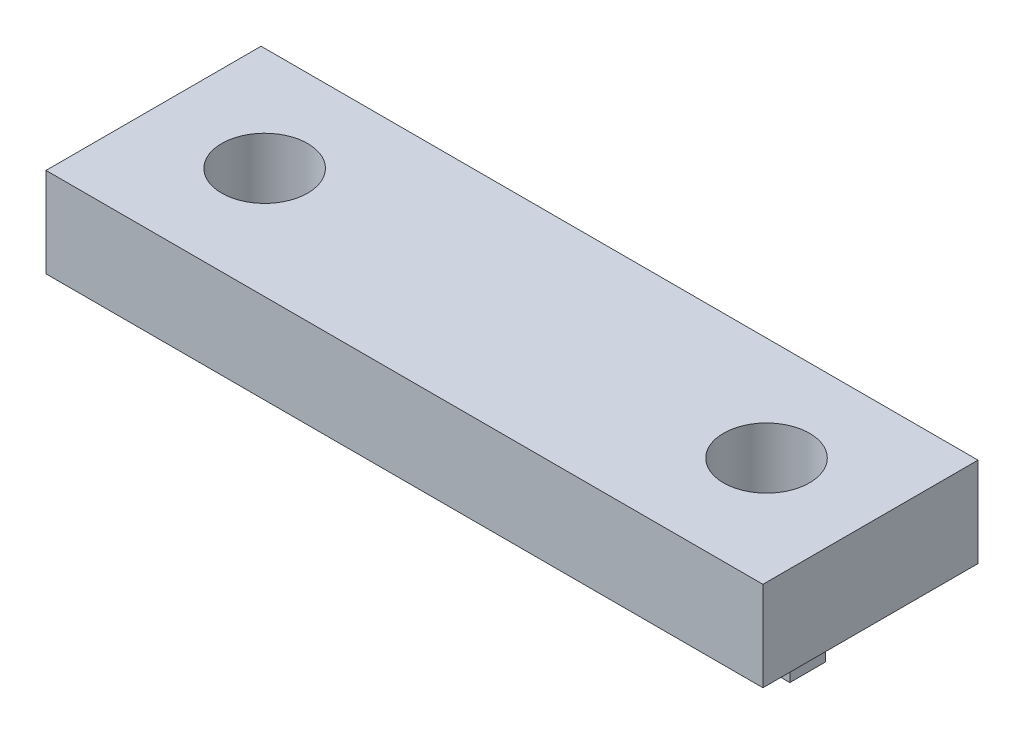
from build123d import *

# Parameters (mm, degrees)
BOSS_EXTRU_1_DEPTH      = 40
ESQUISSE2_R             = 2.4
ENL_V_MAT_EXTRU_1_DEPTH = 40
ESQUISSE3_W             = 8.5
ESQUISSE3_H             = 9
ENL_V_MAT_EXTRU_2_DEPTH = 40
ESQUISSE4_R             = 2.5
ENL_V_MAT_EXTRU_3_DEPTH = 40


with BuildPart() as part:
    # Esquisse1 → Boss.-Extru.1 (new body)
    with BuildSketch(Plane(origin=(0, 0, 0), x_dir=(0, 0, -1), z_dir=(1, 0, 0))):
        Polygon((0, 0), (0, 14), (-12, 14), (-12, 9), (-2, 9), (-2, 0), align=None)
    extrude(amount=BOSS_EXTRU_1_DEPTH)

    # Esquisse2 → Enlèv. mat.-Extru.1 (cut)
    with BuildSketch(Plane(origin=(0, 14, 0), x_dir=(1, 0, 0), z_dir=(0, 1, 0))):
        with Locations(Location((34, -5.8, 0), (0, 0, 270))):  # turned: the seam where the file's is
            Circle(ESQUISSE2_R)
        with Locations(Location((6, -5.8, 0), (0, 0, 270))):  # turned: the seam where the file's is
            Circle(ESQUISSE2_R)
    extrude(amount=-ENL_V_MAT_EXTRU_1_DEPTH, mode=Mode.SUBTRACT)

    # Esquisse3 → Enlèv. mat.-Extru.2 (cut)
    with BuildSketch(Plane.XY.offset(2)):
        with Locations((4.25, 4.5)):
            Rectangle(ESQUISSE3_W, ESQUISSE3_H)
        with Locations((35.75, 4.5)):
            Rectangle(ESQUISSE3_W, ESQUISSE3_H)
    extrude(amount=-ENL_V_MAT_EXTRU_2_DEPTH, mode=Mode.SUBTRACT)

    # Esquisse4 → Enlèv. mat.-Extru.3 (cut)
    with BuildSketch(Plane.XY.offset(2)):
        with Locations((26.5, 5)):
            Circle(ESQUISSE4_R)
        with Locations((13.5, 5)):
            Circle(ESQUISSE4_R)
    extrude(amount=-ENL_V_MAT_EXTRU_3_DEPTH, mode=Mode.SUBTRACT)


solid = part.part
